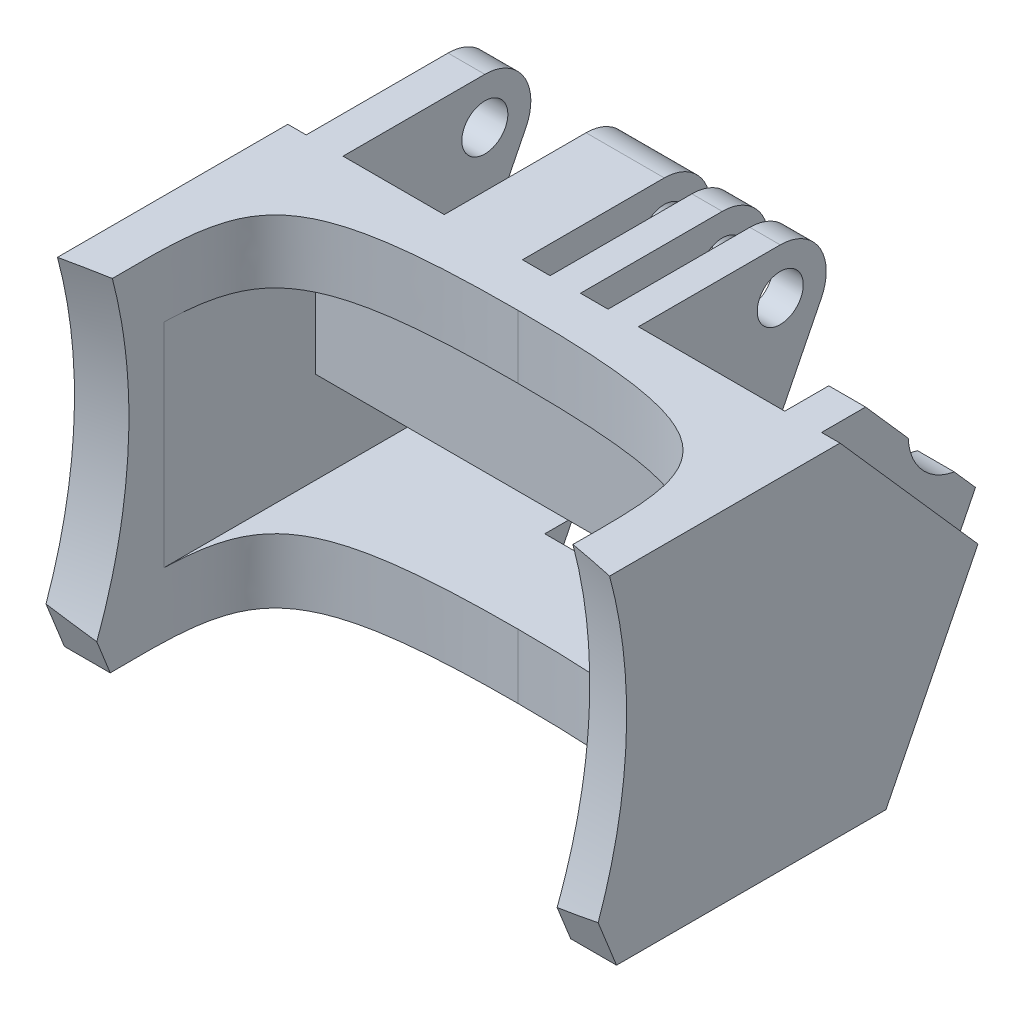
from build123d import *

# Parameters (mm, degrees)
BOSS_EXTRUDE1_DEPTH     = 37
CUT_EXTRUDE1_DEPTH      = 1.0000001
CUT_EXTRUDE1_DEPTH_BACK = 61.0000001
SKETCH4_W               = 4
SKETCH4_H               = 22.671568097
SKETCH4_W_2             = 3.3
SKETCH4_W_3             = 8.5
BOSS_EXTRUDE2_DEPTH     = 22
SKETCH5_R               = 2.5
CUT_EXTRUDE3_DEPTH      = 61.0000001
CUT_EXTRUDE4_DEPTH      = 5
CUT_EXTRUDE5_START      = -5
CUT_EXTRUDE5_DEPTH      = 50
CUT_EXTRUDE6_DEPTH      = 5
CUT_EXTRUDE7_DEPTH      = 61.0000001
SKETCH13_W              = 15
SKETCH13_H              = 7
CUT_EXTRUDE8_DEPTH      = 8
SKETCH14_W              = 15
SKETCH14_H              = 3
CUT_EXTRUDE9_DEPTH      = 13


with BuildPart() as part:
    # Sketch1 → Boss-Extrude1 (new body)
    with BuildSketch(Plane(origin=(0, 0, 0), x_dir=(1, 0, 0), z_dir=(0, 1, 0))):
        with BuildLine():
            Line((-30, -13.426573427), (-25, -13.426573427))
            add(Edge.make_bspline(
                [(-25, -13.426573427), (-25, 4.430411277), (-27.179958799, 9.573426573), (0, 9.573426573)],
                knots=[0, 0, 0, 0, 1, 1, 1, 1], degree=3))
            add(Edge.make_bspline(
                [(25, -13.426573427), (25, 4.430411277), (27.179958799, 9.573426573), (0, 9.573426573)],
                knots=[0, 0, 0, 0, 1, 1, 1, 1], degree=3))
            Line((25, -13.426573427), (30, -13.426573427))
            Line((30, -13.426573427), (30, 29.573426573))
            Line((30, 29.573426573), (-30, 29.573426573))
            Line((-30, 29.573426573), (-30, -13.426573427))
        make_face()
    extrude(amount=BOSS_EXTRUDE1_DEPTH)

    # Sketch3 → Cut-Extrude1 (cut, two sides)
    with BuildSketch(Plane(origin=(30, 0, 0), x_dir=(0, 0, -1), z_dir=(1, 0, 0))) as cut_extrude1_sk:
        Polygon((-57.646837501, 118.849632618), (14.573426573, 37), (29.573426573, 20), (19.573426573, 0), (-29.242818474, -97.632490095), (187.21482124, -69.231683414), (158.810802213, 147.250439298), align=None)
    extrude(amount=CUT_EXTRUDE1_DEPTH, mode=Mode.SUBTRACT)
    extrude(cut_extrude1_sk.sketch, amount=-CUT_EXTRUDE1_DEPTH_BACK, mode=Mode.SUBTRACT)

    # Sketch4 → Boss-Extrude2 (add)
    with BuildSketch(Plane(origin=(0, 23.426505401, -26.550039455), x_dir=(-1, 0, 0), z_dir=(0, 0.661621637, -0.749837855))):
        with Locations((-26, 6.766122252)):
            Rectangle(SKETCH4_W, SKETCH4_H)
        with Locations((-6.45, 6.766122252)):
            Rectangle(SKETCH4_W_2, SKETCH4_H)
        with Locations((-0.15, 6.766122252)):
            Rectangle(SKETCH4_W_2, SKETCH4_H)
        with Locations((8.75, 6.766122252)):
            Rectangle(SKETCH4_W_3, SKETCH4_H)
        with Locations((26, 6.766122252)):
            Rectangle(SKETCH4_W, SKETCH4_H)
    extrude(amount=BOSS_EXTRUDE2_DEPTH)

    # Sketch5 → Cut-Extrude3 (cut, through all)
    with BuildSketch(Plane.ZY.offset(30)):
        with Locations((-29.98325663, 32)):
            Circle(SKETCH5_R)
        with BuildLine():
            Line((-29.573426573, 20), (-34.455392585, 29.763932023))
            ThreePointArc((-34.455392585, 29.763932023), (-34.236510671, 34.628655561), (-29.98325663, 37))
            Line((-29.98325663, 37), (-14.573426573, 37))
            Line((-14.573426573, 37), (-31.069859391, 51.555676016))
            Line((-31.069859391, 51.555676016), (-46.069859391, 34.555676016))
            Line((-46.069859391, 34.555676016), (-29.573426573, 20))
        make_face()
    extrude(amount=-CUT_EXTRUDE3_DEPTH, mode=Mode.SUBTRACT)

    # Sketch6 → Cut-Extrude4 (cut)
    with BuildSketch(Plane(origin=(28, 0, 0), x_dir=(0, 0, -1), z_dir=(1, 0, 0))):
        with BuildLine():
            Line((19.357697554, 37), (23.988388994, 31.751883035))
            ThreePointArc((23.988388994, 31.751883035), (25.484229497, 28.030270177), (28.990627874, 26.082678972))
            Line((28.990627874, 26.082678972), (31.303907567, 23.460961986))
            Line((31.303907567, 23.460961986), (39.342476381, 37))
            Line((39.342476381, 37), (19.357697554, 37))
        make_face()
    extrude(amount=-CUT_EXTRUDE4_DEPTH, mode=Mode.SUBTRACT)

    # Sketch8 → Cut-Extrude5 (cut)
    with BuildSketch(Plane.ZY.offset(30).offset(CUT_EXTRUDE5_START)):
        Polygon((-37.173999373, 17), (-24.143524451, 17), (-12.559294899, 17), (-12.559294899, 30.128793492), (16.915989795, 30.128793492), (24.04096029, 17), (24.04096029, 7), (-37.173999373, 7), align=None)
    extrude(amount=-CUT_EXTRUDE5_DEPTH, mode=Mode.SUBTRACT)

    # Sketch9 → Cut-Extrude6 (cut)
    with BuildSketch(Plane.ZY.offset(13)):
        Polygon((-28.681032795, 27.598669169), (-25.520480402, 30.927093507), (-26.822704237, 35.328424338), (-31.285480464, 36.401330831), (-34.446032857, 33.072906493), (-33.143809023, 28.671575662), align=None)
    extrude(amount=-CUT_EXTRUDE6_DEPTH, mode=Mode.SUBTRACT)

    # Sketch11 → Cut-Revolve1 (revolve, cut)
    with BuildSketch(Plane(origin=(0, 23, 0), x_dir=(1, 0, 0), z_dir=(0, 1, 0))):
        with BuildLine():
            Line((-50.031983596, -14.333391692), (49.362026098, -14.090860868))
            ThreePointArc((49.362026098, -14.090860868), (-0.356252807, -5.493589451), (-50.031983596, -14.333391692))
        make_face()
    revolve(axis=Axis((-30, 23, 62.493589451), (1, 0, 0)), mode=Mode.SUBTRACT)

    # Sketch12 → Cut-Extrude7 (cut, through all)
    with BuildSketch(Plane(origin=(30, 0, 0), x_dir=(0, 0, -1), z_dir=(1, 0, 0))):
        Polygon((-11.703889749, 5), (-9.703889749, 0), (-17.42565217, 0), align=None)
    extrude(amount=-CUT_EXTRUDE7_DEPTH, mode=Mode.SUBTRACT)

    # Sketch13 → Cut-Extrude8 (cut)
    with BuildSketch(Plane.XY.offset(-28)):
        with Locations((0, 3.5)):
            Rectangle(SKETCH13_W, SKETCH13_H)
    extrude(amount=CUT_EXTRUDE8_DEPTH, mode=Mode.SUBTRACT)

    # Sketch14 → Cut-Extrude9 (cut)
    with BuildSketch(Plane.XY.offset(-30)):
        with Locations((0, 18.5)):
            Rectangle(SKETCH14_W, SKETCH14_H)
    extrude(amount=CUT_EXTRUDE9_DEPTH, mode=Mode.SUBTRACT)


solid = part.part
